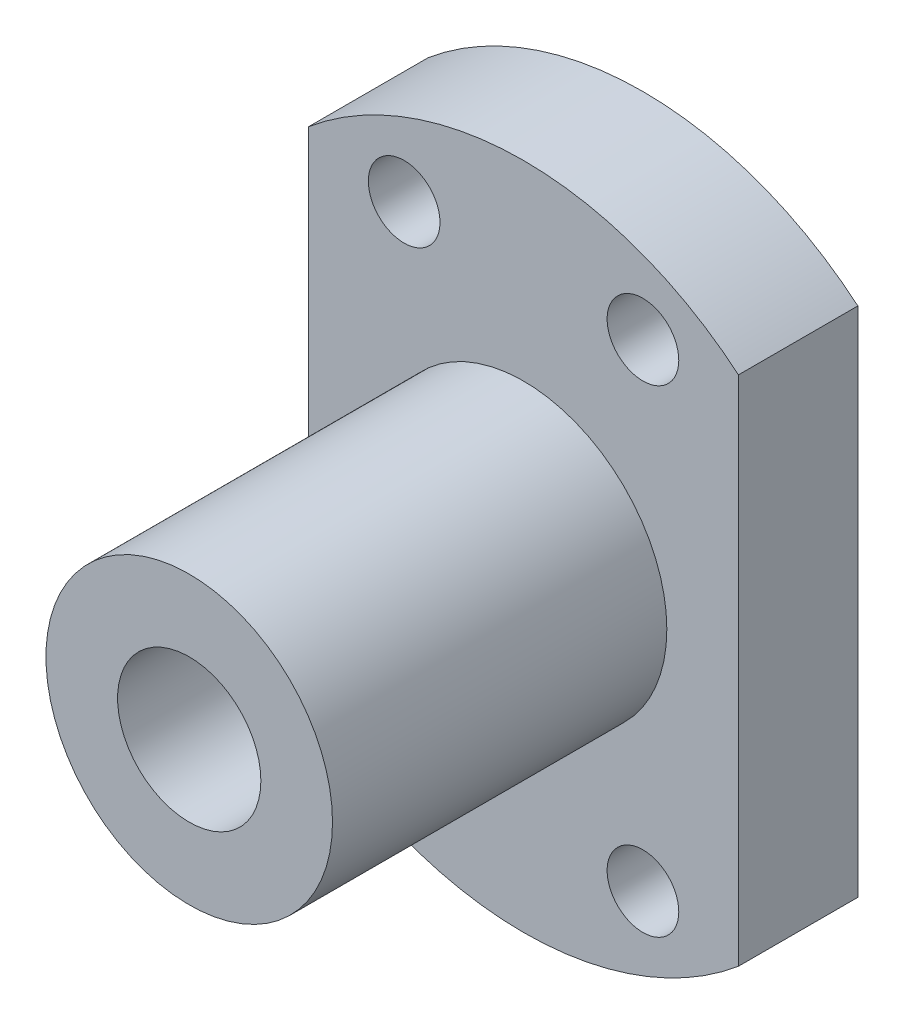
from build123d import *

# Parameters (mm, degrees)
SKETCH1_R           = 3
SKETCH1_R_2         = 1.5
BOSS_EXTRUDE1_DEPTH = 5
SKETCH2_R           = 6
SKETCH2_R_2         = 3
BOSS_EXTRUDE2_DEPTH = 14


with BuildPart() as part:
    # Sketch1 → Boss-Extrude1 (new body)
    with BuildSketch(Plane.XY):
        with BuildLine():
            Line((-9, 10.723805295), (-9, -10.723805295))
            ThreePointArc((-9, -10.723805295), (0, -14), (9, -10.723805295))
            Line((9, -10.723805295), (9, 10.723805295))
            ThreePointArc((9, 10.723805295), (0, 14), (-9, 10.723805295))
        make_face()
        Circle(SKETCH1_R, mode=Mode.SUBTRACT)
        with Locations((-5, 10)):
            Circle(SKETCH1_R_2, mode=Mode.SUBTRACT)
        with Locations((5, 10)):
            Circle(SKETCH1_R_2, mode=Mode.SUBTRACT)
        with Locations((-5, -10)):
            Circle(SKETCH1_R_2, mode=Mode.SUBTRACT)
        with Locations((5, -10)):
            Circle(SKETCH1_R_2, mode=Mode.SUBTRACT)
    extrude(amount=BOSS_EXTRUDE1_DEPTH)

    # Sketch2 → Boss-Extrude2 (add)
    with BuildSketch(Plane.XY.offset(5)):
        Circle(SKETCH2_R)
        Circle(SKETCH2_R_2, mode=Mode.SUBTRACT)
    extrude(amount=BOSS_EXTRUDE2_DEPTH)


solid = part.part
